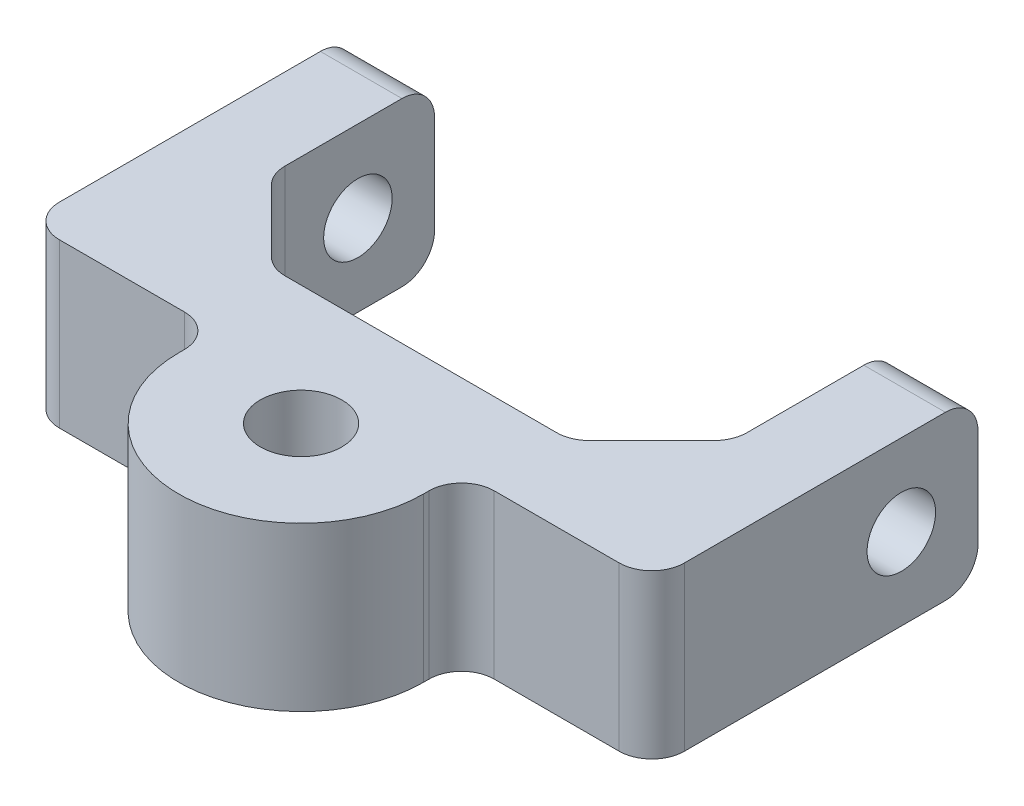
from build123d import *

# Parameters (mm, degrees)
BOSS_EXTRUDE1_DEPTH = 12.7
SKETCH2_R           = 2.667
CUT_EXTRUDE1_DEPTH  = 49.6664
BOSS_EXTRUDE3_DEPTH = 12.7
BOSS_EXTRUDE4_DEPTH = 12.7
CUT_EXTRUDE2_REACH  = 14.7
SKETCH5_R           = 3.175
FILLET1_R           = 2.54
RR_R                = 2.54
FILLET3_R           = 2.54


with BuildPart() as part:
    # Sketch1 → Boss-Extrude1 (new body)
    with BuildSketch(Plane(origin=(0, 0, 0), x_dir=(1, 0, 0), z_dir=(0, 1, 0))):
        Polygon((-6.35, -6.35), (-6.35, 19.05), (0, 19.05), (0, 0), (35.9664, 0), (35.9664, 19.05), (42.3164, 19.05), (42.3164, -6.35), align=None)
    extrude(amount=BOSS_EXTRUDE1_DEPTH)

    # Sketch2 → Cut-Extrude1 (cut, through all)
    with BuildSketch(Plane(origin=(42.3164, 0, 0), x_dir=(0, 0, -1), z_dir=(1, 0, 0))):
        with Locations((13.081, 6.35)):
            Circle(SKETCH2_R)
    extrude(amount=-CUT_EXTRUDE1_DEPTH, mode=Mode.SUBTRACT)

    # Sketch3 → Boss-Extrude3 (add)
    with BuildSketch(Plane(origin=(0, 12.7, 0), x_dir=(1, 0, 0), z_dir=(0, 1, 0))):
        Polygon((0, 0), (6.35, 0), (0, 6.35), align=None)
        Polygon((35.9664, 6.35), (29.6164, 0), (35.9664, 0), align=None)
    extrude(amount=-BOSS_EXTRUDE3_DEPTH)

    # Sketch4 → Boss-Extrude4 (add)
    with BuildSketch(Plane.XZ):
        with BuildLine():
            Line((27.5082, 9.32613509), (27.5082, 6.35))
            Line((27.5082, 6.35), (8.4582, 6.35))
            Line((8.4582, 6.35), (8.4582, 9.32613509))
            ThreePointArc((8.4582, 9.32613509), (17.9832, 18.85113509), (27.5082, 9.32613509))
        make_face()
    extrude(amount=-BOSS_EXTRUDE4_DEPTH)

    # Sketch5 → Cut-Extrude2 (cut, up to next)
    with BuildSketch(Plane.XZ, mode=Mode.PRIVATE) as cut_extrude2_sk1:
        with Locations((17.9832, 9.32613509)):
            Circle(SKETCH5_R)
    cut_extrude2_tool1 = extrude(cut_extrude2_sk1.sketch, amount=-CUT_EXTRUDE2_REACH, mode=Mode.PRIVATE) & part.part
    add(cut_extrude2_tool1.solids().sort_by_distance((17.9832, 0, 9.326135))[0], mode=Mode.SUBTRACT)

    # Fillet1
    fillet1_edges = [part.edges().sort_by_distance(p)[0] for p in [
        (42.3164, 6.35, 6.35),
        (-6.35, 6.35, 6.35),
        (8.4582, 6.35, 6.35),
        (27.5082, 6.35, 6.35),
    ]]
    fillet(fillet1_edges, radius=FILLET1_R)

    # rr
    rr_edges = [part.edges().sort_by_distance(p)[0] for p in [
        (0, 6.35, -6.35),
        (6.35, 6.35, 0),
        (35.9664, 6.35, -6.35),
        (29.6164, 6.35, 0),
    ]]
    fillet(rr_edges, radius=RR_R)

    # Fillet3
    fillet3_edges = [part.edges().sort_by_distance(p)[0] for p in [
        (-3.175, 0, -19.05),
        (39.1414, 12.7, -19.05),
        (-3.175, 12.7, -19.05),
        (39.1414, 0, -19.05),
    ]]
    fillet(fillet3_edges, radius=FILLET3_R)


solid = part.part
